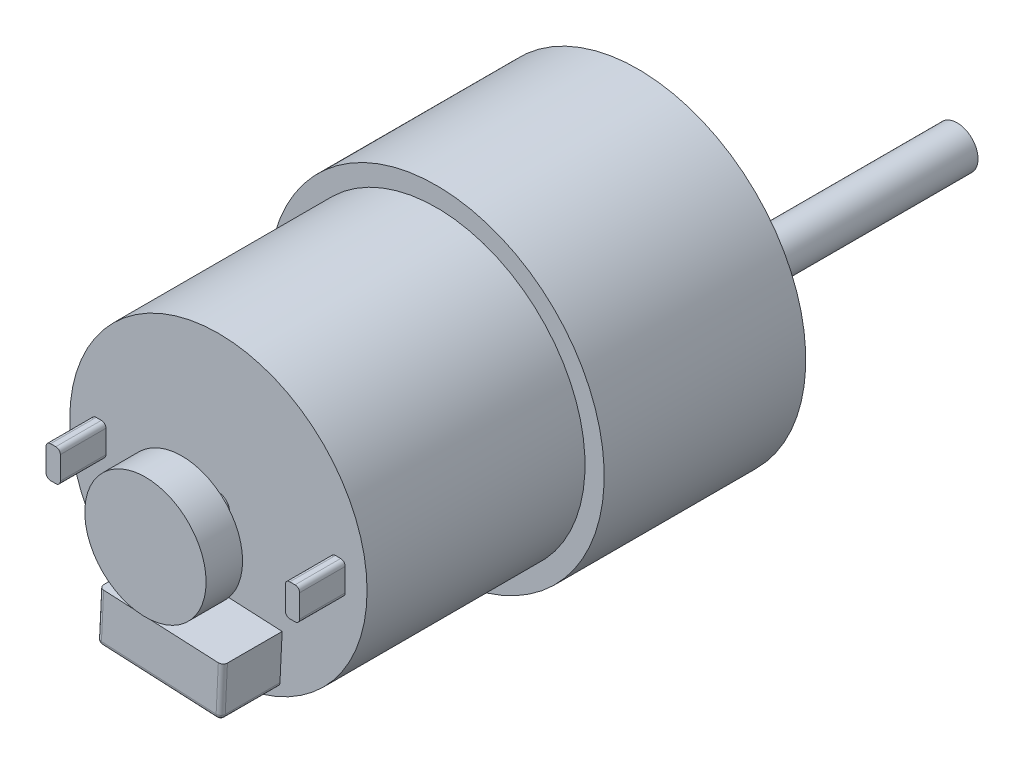
from build123d import *

# Parameters (mm, degrees)
SKETCH1_R            = 16.3
BOSS_EXTRUDE1_DEPTH  = 46
SKETCH2_R            = 18.4
BOSS_EXTRUDE2_DEPTH  = 22.1
SKETCH3_R            = 5.9
SKETCH3_R_2          = 2.289263955330087
BOSS_EXTRUDE3_DEPTH  = 5.5
SKETCH4_R            = 2.289263955330087
BOSS_EXTRUDE4_DEPTH  = 35
SKETCH5_R            = 15.4
BOSS_EXTRUDE5_DEPTH  = 0.02
SKETCH7_R            = 1.219257325052135
BOSS_EXTRUDE6_DEPTH  = 4
SKETCH8_R            = 6.650000000000001
BOSS_EXTRUDE7_DEPTH  = 4
BOSS_EXTRUDE9_DEPTH  = 6.5
FILLET3_R            = 0.5
FILLET4_R            = 0.5
BOSS_EXTRUDE10_DEPTH = 5


with BuildPart() as part:
    # Sketch1 → Boss-Extrude1 (new body)
    with BuildSketch(Plane.XY):
        Circle(SKETCH1_R)
    extrude(amount=BOSS_EXTRUDE1_DEPTH)

    # Sketch2 → Boss-Extrude2 (add)
    with BuildSketch(Plane(origin=(0, 0, 0), x_dir=(-1, 0, 0), z_dir=(0, 0, -1))):
        Circle(SKETCH2_R)
    extrude(amount=-BOSS_EXTRUDE2_DEPTH)

    # Sketch3 → Boss-Extrude3 (add)
    with BuildSketch(Plane(origin=(0, 0, 0), x_dir=(-1, 0, 0), z_dir=(0, 0, -1))):
        with Locations(Location((3.05e-15, -6.499999999999999, 0), (0, 0, 180))):
            Circle(SKETCH3_R)
        with Locations((3.05e-15, -6.499999999999999)):
            Circle(SKETCH3_R_2, mode=Mode.SUBTRACT)
    extrude(amount=BOSS_EXTRUDE3_DEPTH)

    # Sketch4 → Boss-Extrude4 (add)
    with BuildSketch(Plane(origin=(0, 0, 0), x_dir=(-1, 0, 0), z_dir=(0, 0, -1))):
        with Locations((3.05e-15, -6.499999999999999)):
            Circle(SKETCH4_R)
    extrude(amount=BOSS_EXTRUDE4_DEPTH)

    # Sketch5 → Boss-Extrude5 (add)
    with BuildSketch(Plane(origin=(0, 0, 0), x_dir=(-1, 0, 0), z_dir=(0, 0, -1))):
        with Locations(Location((0, 0, 0), (0, 0, 180))):
            Circle(SKETCH5_R)
    extrude(amount=BOSS_EXTRUDE5_DEPTH)

    # Sketch7 → Boss-Extrude6 (add)
    with BuildSketch(Plane.XY.offset(46)):
        Circle(SKETCH7_R)
    extrude(amount=BOSS_EXTRUDE6_DEPTH)

    # Sketch8 → Boss-Extrude7 (add)
    with BuildSketch(Plane.XY.offset(50)):
        Circle(SKETCH8_R)
    extrude(amount=BOSS_EXTRUDE7_DEPTH)

    # Sketch9 → Boss-Extrude9 (add)
    with BuildSketch(Plane.XY.offset(46)):
        Polygon((6.723733828483781, -14.005985299746056), (-6.848294391516219, -13.347034241416539), (-6.581571792597097, -7.853505406939939), (6.990456427402904, -8.512456465269457), align=None)
    extrude(amount=BOSS_EXTRUDE9_DEPTH)

    # Fillet3
    fillet3_edges = [part.edges().sort_by_distance(p)[0] for p in [
        (-6.848294391516219, -13.347034241416539, 49.25),
        (-6.714933092056658, -10.60026982417824, 52.5),
        (-0.06228028151621867, -13.676509770581298, 52.5),
    ]]
    fillet(fillet3_edges, radius=FILLET3_R)

    # Fillet4
    fillet4_edges = [part.edges().sort_by_distance(p)[0] for p in [
        (6.723733828483781, -14.005985299746056, 49),
        (6.869218882439666, -11.009515026395185, 52.5),
        (6.730835759440846, -13.859710995839299, 52.35355339059328),
    ]]
    fillet(fillet4_edges, radius=FILLET4_R)

    # Sketch10 → Boss-Extrude10 (add)
    with BuildSketch(Plane.XY.offset(46)):
        with BuildLine():
            Line((-13.903663432832225, 1.1177381723245752), (-13.903663432832225, -1.3957121223426263))
            ThreePointArc((-13.903663432832225, -1.3957121223426263), (-13.757216823425498, -1.7492655129359036), (-13.403663432832222, -1.8957121223426299))
            Line((-13.403663432832222, -1.8957121223426299), (-12.829664566070878, -1.8957121223426299))
            ThreePointArc((-12.829664566070878, -1.8957121223426299), (-12.476111175477602, -1.7492655129359036), (-12.329664566070875, -1.3957121223426263))
            Line((-12.329664566070875, -1.3957121223426263), (-12.329664566070875, 1.1177381723245752))
            ThreePointArc((-12.329664566070875, 1.1177381723245752), (-12.476111175477602, 1.4712915629178525), (-12.829664566070878, 1.6177381723245787))
            Line((-12.829664566070878, 1.6177381723245787), (-13.403663432832222, 1.6177381723245787))
            ThreePointArc((-13.403663432832222, 1.6177381723245787), (-13.757216823425498, 1.4712915629178525), (-13.903663432832225, 1.1177381723245752))
        make_face()
        with BuildLine():
            Line((13.403663432832222, -1.8957121223426299), (12.829664566070878, -1.8957121223426299))
            ThreePointArc((12.829664566070878, -1.8957121223426299), (12.476111175477602, -1.7492655129359036), (12.329664566070875, -1.3957121223426263))
            Line((12.329664566070875, -1.3957121223426263), (12.329664566070875, 1.1177381723245752))
            ThreePointArc((12.329664566070875, 1.1177381723245752), (12.476111175477602, 1.4712915629178525), (12.829664566070878, 1.6177381723245787))
            Line((12.829664566070878, 1.6177381723245787), (13.403663432832222, 1.6177381723245787))
            ThreePointArc((13.403663432832222, 1.6177381723245787), (13.757216823425498, 1.4712915629178525), (13.903663432832225, 1.1177381723245752))
            Line((13.903663432832225, 1.1177381723245752), (13.903663432832225, -1.3957121223426263))
            ThreePointArc((13.903663432832225, -1.3957121223426263), (13.757216823425498, -1.7492655129359036), (13.403663432832222, -1.8957121223426299))
        make_face()
    extrude(amount=BOSS_EXTRUDE10_DEPTH)


solid = part.part
